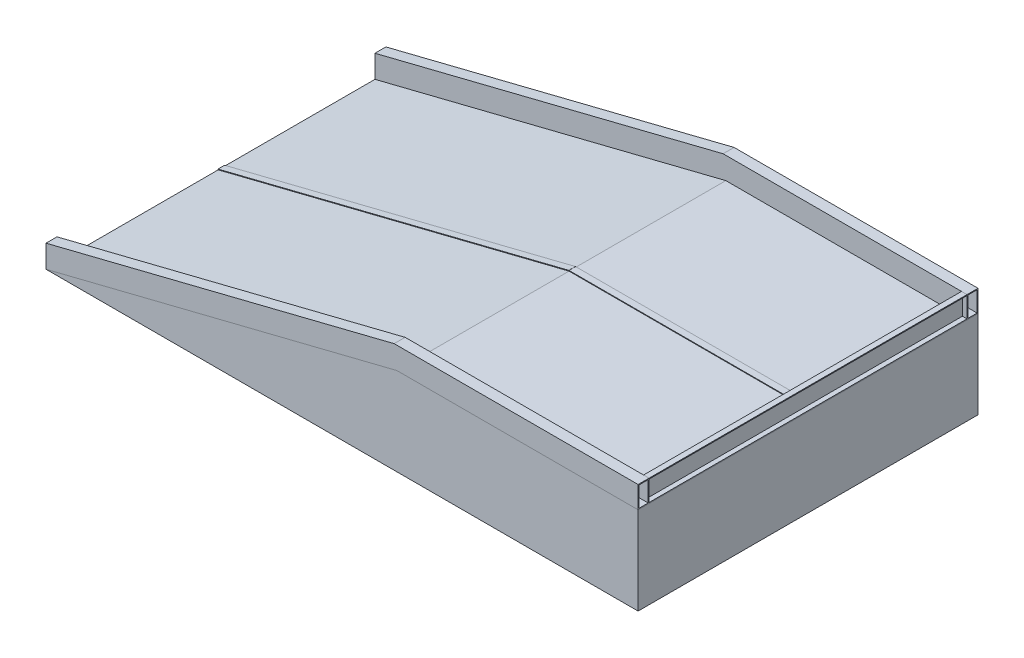
from build123d import *

# Parameters (mm, degrees)
BOSS_EXTRUDE1_DEPTH      = 775
BOSS_EXTRUDE1_DEPTH_BACK = 775
BOSS_EXTRUDE2_DEPTH      = 50
SHELL1_T                 = -4
BOSS_EXTRUDE3_DEPTH      = 50
SHELL2_T                 = -4
SKETCH5_W                = 25
SKETCH5_H                = 1450
BOSS_EXTRUDE4_DEPTH      = 100
SHELL3_T                 = -4
SKETCH7_W                = 1075
SKETCH7_H                = 30
BOSS_EXTRUDE5_DEPTH      = 3
SKETCH8_W                = 1649.242250247
SKETCH8_H                = 30
BOSS_EXTRUDE6_DEPTH      = 3


with BuildPart() as part:
    # Sketch1 → Boss-Extrude1 (new, two sides: drawn at the far end of the back side and taken through both)
    with BuildSketch(Plane.XY.offset(-BOSS_EXTRUDE1_DEPTH_BACK)):
        Polygon((-2700, 0), (0, 0), (0, 400), (-1100, 400), align=None)
    extrude(amount=BOSS_EXTRUDE1_DEPTH + BOSS_EXTRUDE1_DEPTH_BACK)


with BuildPart() as body_2:
    # Sketch3 → Boss-Extrude2 (new body)
    with BuildSketch(Plane.XY.offset(775)):
        Polygon((-2700, 103.07764064), (-2700, 0), (-1100, 400), (0, 400), (0, 500), (-1112.310562562, 500), align=None)
    extrude(amount=-BOSS_EXTRUDE2_DEPTH)

    # Shell1
    shell1_openings = [body_2.faces().sort_by_distance(p)[0] for p in [
        (0, 450, 750),
        (-2700, 51.53882032, 750),
    ]]
    offset(amount=SHELL1_T, openings=shell1_openings, kind=Kind.INTERSECTION)


with BuildPart() as body_3:
    # Sketch4 → Boss-Extrude3 (new body)
    with BuildSketch(Plane(origin=(0, 0, -775), x_dir=(-1, 0, 0), z_dir=(0, 0, -1))):
        Polygon((2700, 0), (2700, 103.07764064), (1112.310562562, 500), (0, 500), (0, 400), (1100, 400), align=None)
    extrude(amount=-BOSS_EXTRUDE3_DEPTH)

    # Shell2
    shell2_openings = [body_3.faces().sort_by_distance(p)[0] for p in [
        (0, 450, -750),
        (-2700, 51.53882032, -750),
    ]]
    offset(amount=SHELL2_T, openings=shell2_openings, kind=Kind.INTERSECTION)


with BuildPart() as body_4:
    # Sketch5 → Boss-Extrude4 (new body)
    with BuildSketch(Plane(origin=(0, 400, 0), x_dir=(1, 0, 0), z_dir=(0, 1, 0))):
        with Locations((-12.5, 0)):
            Rectangle(SKETCH5_W, SKETCH5_H)
    extrude(amount=BOSS_EXTRUDE4_DEPTH)

    # Shell3
    shell3_openings = [body_4.faces().sort_by_distance(p)[0] for p in [
        (-12.5, 450, -725),
        (0, 450, 0),
        (-12.5, 450, 725),
    ]]
    offset(amount=SHELL3_T, openings=shell3_openings, kind=Kind.INTERSECTION)


with BuildPart() as body_5:
    # Sketch7 → Boss-Extrude5 (new body)
    with BuildSketch(Plane(origin=(0, 400, 0), x_dir=(1, 0, 0), z_dir=(0, 1, 0))):
        with Locations((-562.5, 25)):
            Rectangle(SKETCH7_W, SKETCH7_H)
    extrude(amount=BOSS_EXTRUDE5_DEPTH)


with BuildPart() as body_6:
    # Sketch8 → Boss-Extrude6 (new body)
    with BuildSketch(Plane(origin=(-158.823529412, 635.294117647, 0), x_dir=(0.970142500145332, 0.24253562503633297, 0), z_dir=(-0.24253562503633297, 0.970142500145332, 0))):
        with Locations((-1794.763625269, 25)):
            Rectangle(SKETCH8_W, SKETCH8_H)
    extrude(amount=BOSS_EXTRUDE6_DEPTH)


solid = Compound([part.part, body_2.part, body_3.part, body_4.part, body_5.part, body_6.part])
